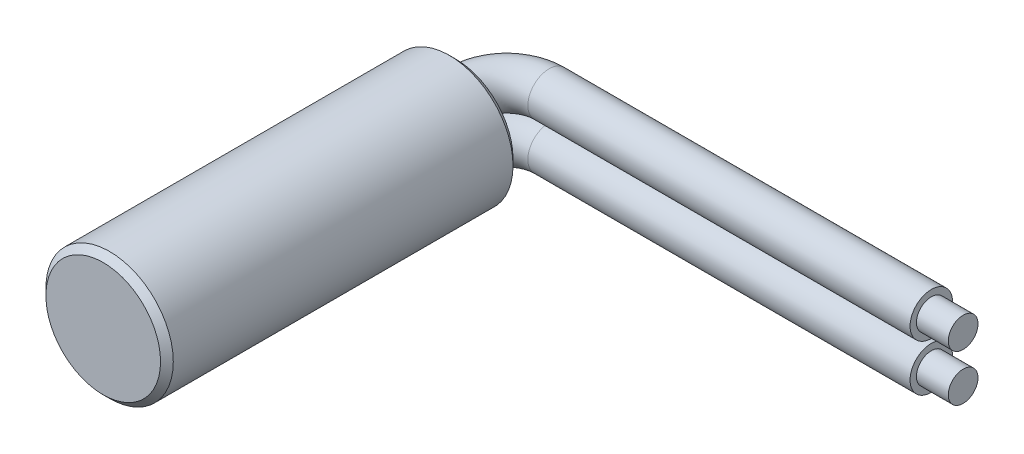
from build123d import *

# Parameters (mm, degrees)
SKETCH1_R           = 3
CASING_DEPTH        = 16.6
CASING_CHAMFER_SIZE = 0.3
SKETCH3_R           = 1
SKETCH4_R           = 0.7
EXPOSED_WIRE_DEPTH  = 1.5


with BuildPart() as part:
    # Sketch1 → Casing (new body)
    with BuildSketch(Plane.XY):
        Circle(SKETCH1_R)
    extrude(amount=CASING_DEPTH)

    # Casing Chamfer
    casing_chamfer_edges = [part.edges().sort_by_distance(p)[0] for p in [
        (-3, 0, 0),
        (-3, 0, 16.6),
    ]]
    chamfer(casing_chamfer_edges, length=CASING_CHAMFER_SIZE)

    # Wire 2: sweep along a path in Sketch2
    with BuildLine(Plane(origin=(0, 0, 0), x_dir=(1, 0, 0), z_dir=(0, 1, 0))) as wire_2_path:
        Line((0, 0), (0, 0.4))
        ThreePointArc((0, 0.4), (0.585786438, 1.814213562), (2, 2.4))
        Line((2, 2.4), (20, 2.4))
    # Sketch3 → Wire 2 (sweep)
    with BuildSketch(Plane(origin=(0, 0, 0), x_dir=(-1, 0, 0), z_dir=(0, 0, -1))):
        with Locations((0, -1.1)):
            Circle(SKETCH3_R)
        with Locations((0, 1.1)):
            Circle(SKETCH3_R)
    sweep(path=wire_2_path.line)

    # Sketch4 → Exposed Wire (add)
    with BuildSketch(Plane(origin=(20, 0, 0), x_dir=(0, 0, -1), z_dir=(1, 0, 0))):
        with Locations((2.4, 1.1)):
            Circle(SKETCH4_R)
        with Locations((2.4, -1.1)):
            Circle(SKETCH4_R)
    extrude(amount=EXPOSED_WIRE_DEPTH)


solid = part.part
